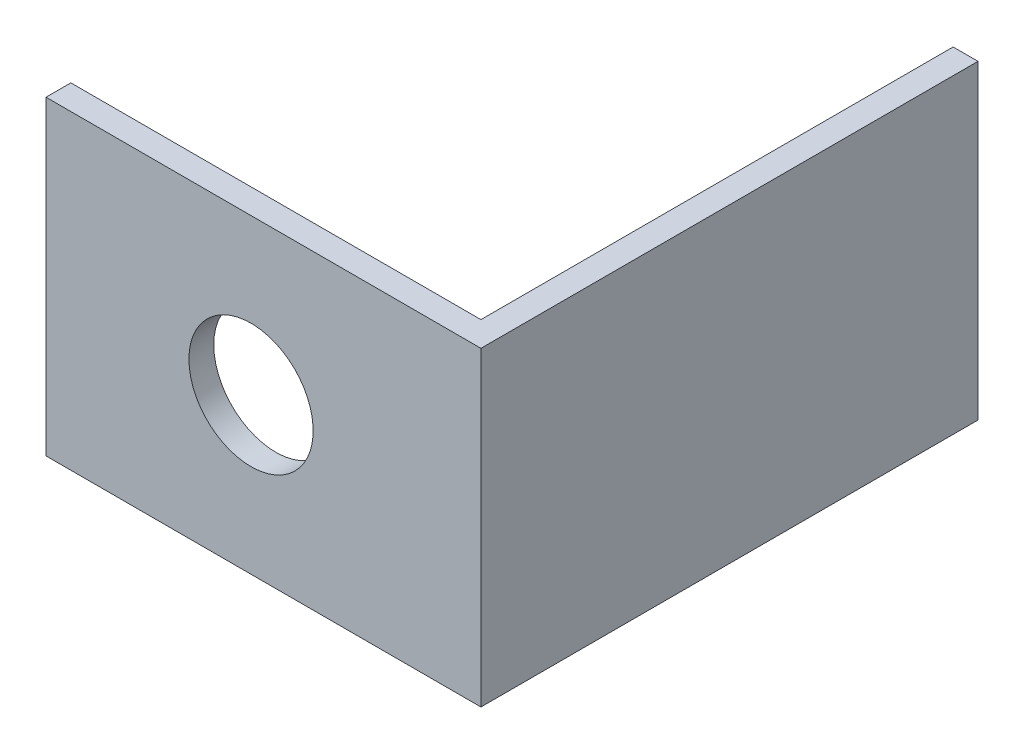
from build123d import *

# Parameters (mm, degrees)
BOSS_EXTRUDE1_DEPTH = 31.75
SKETCH2_R           = 6.35
CUT_EXTRUDE1_DEPTH  = 31.75


with BuildPart() as part:
    # Sketch1 → Boss-Extrude1 (new body)
    with BuildSketch(Plane(origin=(0, 0, 0), x_dir=(1, 0, 0), z_dir=(0, 1, 0))):
        Polygon((0, 0), (44.45, 0), (44.45, 50.8), (41.91, 50.8), (41.91, 2.54), (0, 2.54), align=None)
    extrude(amount=BOSS_EXTRUDE1_DEPTH)

    # Sketch2 → Cut-Extrude1 (cut)
    with BuildSketch(Plane(origin=(0, 0, -2.54), x_dir=(-1, 0, 0), z_dir=(0, 0, -1))):
        with Locations((-20.955, 15.875)):
            Circle(SKETCH2_R)
    extrude(amount=-CUT_EXTRUDE1_DEPTH, mode=Mode.SUBTRACT)


solid = part.part
